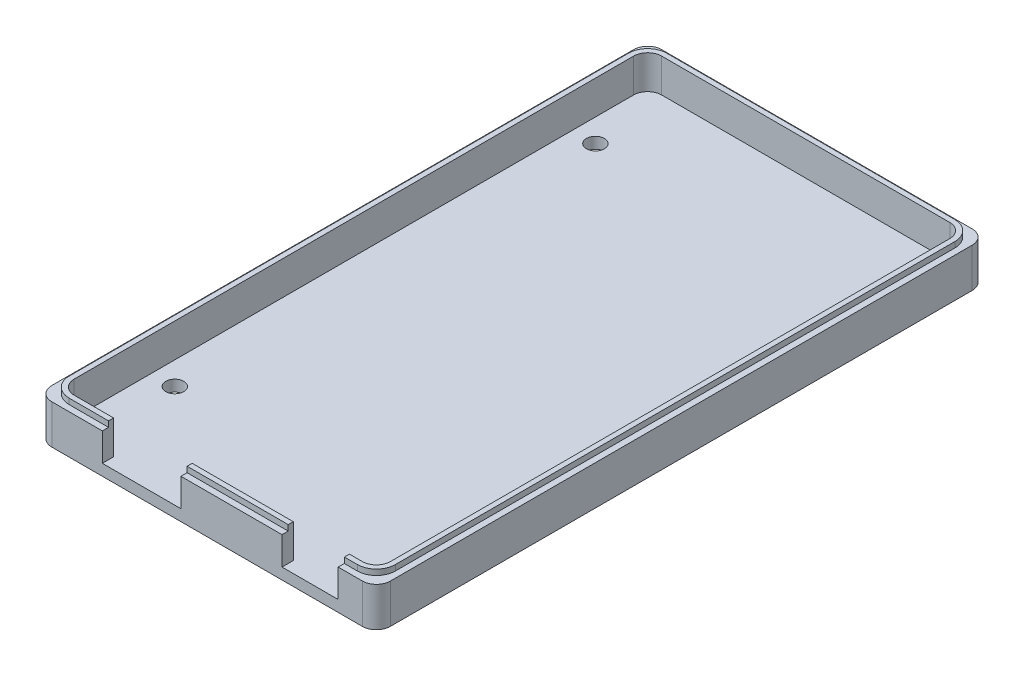
from build123d import *

# Parameters (mm, degrees)
BOSS_EXTRUDE1_DEPTH = 2
SKETCH5_W           = 18
SKETCH5_H           = 2
BOSS_EXTRUDE2_DEPTH = 5
CUT_EXTRUDE1_REACH  = 4
SKETCH6_R           = 1.6
FILLET1_R           = 2.5
SKETCH7_W           = 18
SKETCH7_H           = 0.9
BOSS_EXTRUDE3_DEPTH = 1


with BuildPart() as part:
    # Sketch4 → Boss-Extrude1 (new body)
    with BuildSketch(Plane(origin=(0, 0, 0), x_dir=(1, 0, 0), z_dir=(0, 1, 0))):
        Polygon((-56.8, -3.5), (-56.8, 105.1), (3.5, 105.1), (3.5, -3.5), (-2.3, -3.5), (-14.3, -3.5), (-30.8, -3.5), (-45.8, -3.5), align=None)
    extrude(amount=BOSS_EXTRUDE1_DEPTH)

    # Sketch5 → Boss-Extrude2 (add)
    with BuildSketch(Plane(origin=(0, 2, 0), x_dir=(1, 0, 0), z_dir=(0, 1, 0))):
        Polygon((-45.3, -1.5), (-54.8, -1.5), (-54.8, 103.1), (1.5, 103.1), (1.5, -1.5), (-3.3, -1.5), (-3.3, -3.5), (3.5, -3.5), (3.5, 105.1), (-56.8, 105.1), (-56.8, -3.5), (-45.3, -3.5), align=None)
        with Locations((-22.3, -2.5)):
            Rectangle(SKETCH5_W, SKETCH5_H)
    extrude(amount=BOSS_EXTRUDE2_DEPTH)

    # Sketch6 → Cut-Extrude1 (cut, up to next)
    with BuildSketch(Plane(origin=(0, 2, 0), x_dir=(1, 0, 0), z_dir=(0, 1, 0)), mode=Mode.PRIVATE) as cut_extrude1_sk1:
        with Locations((-2.5, 96.52)):
            Circle(SKETCH6_R)
    cut_extrude1_tool1 = extrude(cut_extrude1_sk1.sketch, amount=-CUT_EXTRUDE1_REACH, mode=Mode.PRIVATE) & part.part
    add(cut_extrude1_tool1.solids().sort_by_distance((-2.5, 2, -96.52))[0], mode=Mode.SUBTRACT)
    # Sketch6 → Cut-Extrude1 (cut, up to next)
    with BuildSketch(Plane(origin=(0, 2, 0), x_dir=(1, 0, 0), z_dir=(0, 1, 0)), mode=Mode.PRIVATE) as cut_extrude1_sk2:
        with Locations((-50.7, 89.7)):
            Circle(SKETCH6_R)
    cut_extrude1_tool2 = extrude(cut_extrude1_sk2.sketch, amount=-CUT_EXTRUDE1_REACH, mode=Mode.PRIVATE) & part.part
    add(cut_extrude1_tool2.solids().sort_by_distance((-50.7, 2, -89.7))[0], mode=Mode.SUBTRACT)
    # Sketch6 → Cut-Extrude1 (cut, up to next)
    with BuildSketch(Plane(origin=(0, 2, 0), x_dir=(1, 0, 0), z_dir=(0, 1, 0)), mode=Mode.PRIVATE) as cut_extrude1_sk3:
        with Locations((-2.5, 13.5)):
            Circle(SKETCH6_R)
    cut_extrude1_tool3 = extrude(cut_extrude1_sk3.sketch, amount=-CUT_EXTRUDE1_REACH, mode=Mode.PRIVATE) & part.part
    add(cut_extrude1_tool3.solids().sort_by_distance((-2.5, 2, -13.5))[0], mode=Mode.SUBTRACT)
    # Sketch6 → Cut-Extrude1 (cut, up to next)
    with BuildSketch(Plane(origin=(0, 2, 0), x_dir=(1, 0, 0), z_dir=(0, 1, 0)), mode=Mode.PRIVATE) as cut_extrude1_sk4:
        with Locations((-50.7, 14.8)):
            Circle(SKETCH6_R)
    cut_extrude1_tool4 = extrude(cut_extrude1_sk4.sketch, amount=-CUT_EXTRUDE1_REACH, mode=Mode.PRIVATE) & part.part
    add(cut_extrude1_tool4.solids().sort_by_distance((-50.7, 2, -14.8))[0], mode=Mode.SUBTRACT)

    # Fillet1
    fillet1_edges = [part.edges().sort_by_distance(p)[0] for p in [
        (3.5, 3.5, 3.5),
        (3.5, 3.5, -105.1),
        (-56.8, 3.5, -105.1),
        (-56.8, 3.5, 3.5),
        (1.5, 4.5, 1.5),
        (-54.8, 4.5, 1.5),
        (-54.8, 4.5, -103.1),
        (1.5, 4.5, -103.1),
    ]]
    fillet(fillet1_edges, radius=FILLET1_R)

    # Sketch7 → Boss-Extrude3 (add)
    with BuildSketch(Plane(origin=(0, 7, 0), x_dir=(1, 0, 0), z_dir=(0, 1, 0))):
        with BuildLine():
            Line((-3.3, -2.4), (-1, -2.4))
            ThreePointArc((-1, -2.4), (1.404163056, -1.404163056), (2.4, 1))
            Line((2.4, 1), (2.4, 100.6))
            ThreePointArc((2.4, 100.6), (1.404163056, 103.004163056), (-1, 104))
            Line((-1, 104), (-52.3, 104))
            ThreePointArc((-52.3, 104), (-54.704163056, 103.004163056), (-55.7, 100.6))
            Line((-55.7, 100.6), (-55.7, 1))
            ThreePointArc((-55.7, 1), (-54.704163056, -1.404163056), (-52.3, -2.4))
            Line((-52.3, -2.4), (-45.3, -2.4))
            Line((-45.3, -2.4), (-45.3, -1.5))
            Line((-45.3, -1.5), (-52.3, -1.5))
            ThreePointArc((-52.3, -1.5), (-54.067766953, -0.767766953), (-54.8, 1))
            Line((-54.8, 1), (-54.8, 100.6))
            ThreePointArc((-54.8, 100.6), (-54.067766953, 102.367766953), (-52.3, 103.1))
            Line((-52.3, 103.1), (-1, 103.1))
            ThreePointArc((-1, 103.1), (0.767766953, 102.367766953), (1.5, 100.6))
            Line((1.5, 100.6), (1.5, 1))
            ThreePointArc((1.5, 1), (0.767766953, -0.767766953), (-1, -1.5))
            Line((-1, -1.5), (-3.3, -1.5))
            Line((-3.3, -1.5), (-3.3, -2.4))
        make_face()
        with Locations((-22.3, -1.95)):
            Rectangle(SKETCH7_W, SKETCH7_H)
    extrude(amount=BOSS_EXTRUDE3_DEPTH)


solid = part.part
